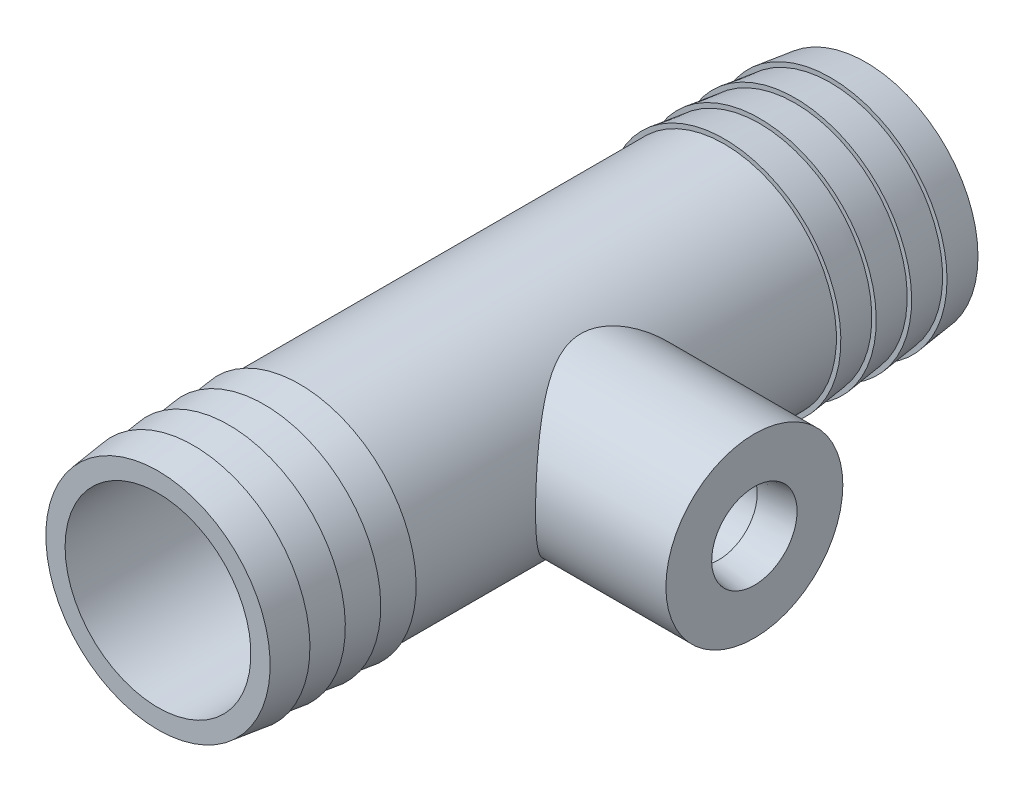
from build123d import *

# Parameters (mm, degrees)
BOSS_EXTRUDE1_DEPTH      = 10
BOSS_EXTRUDE1_DEPTH_BACK = 10
SKETCH1_R                = 10
BOSS_EXTRUDE2_DEPTH      = 40
BOSS_EXTRUDE2_DEPTH_BACK = 40
SKETCH11_R               = 12.675
SKETCH12_R               = 10.5
CUT_EXTRUDE6_DEPTH       = 87.401335837
SKETCH2_R                = 4.825
CUT_EXTRUDE7_DEPTH       = 30
LPATTERN1_COUNT          = 4
LPATTERN1_PITCH          = 4
LPATTERN2_COUNT          = 4
LPATTERN2_PITCH          = 4


with BuildPart() as part:
    # Sketch1 → Boss-Extrude1 (new, two sides: drawn at the far end of the back side and taken through both)
    with BuildSketch(Plane(origin=(0, 0, 0), x_dir=(0, 0, -1), z_dir=(1, 0, 0)).offset(-BOSS_EXTRUDE1_DEPTH_BACK)):
        Circle(SKETCH1_R)
    extrude(amount=BOSS_EXTRUDE1_DEPTH + BOSS_EXTRUDE1_DEPTH_BACK)

    # Sketch11 → Boss-Extrude2 (add, two sides: drawn at the far end of the back side and taken through both)
    with BuildSketch(Plane.XY.offset(-BOSS_EXTRUDE2_DEPTH_BACK)):
        with Locations((-17.400491433, 0)):
            Circle(SKETCH11_R)
    extrude(amount=BOSS_EXTRUDE2_DEPTH + BOSS_EXTRUDE2_DEPTH_BACK)

    # Sketch12 → Cut-Extrude6 (cut, through all)
    with BuildSketch(Plane(origin=(0, 0, -40), x_dir=(-1, 0, 0), z_dir=(0, 0, -1))):
        with Locations((17.400491433, 0)):
            Circle(SKETCH12_R)
    extrude(amount=-CUT_EXTRUDE6_DEPTH, mode=Mode.SUBTRACT)

    # Sketch2 → Cut-Extrude7 (cut)
    with BuildSketch(Plane(origin=(10, 0, 0), x_dir=(0, 0, -1), z_dir=(1, 0, 0))):
        Circle(SKETCH2_R)
    extrude(amount=-CUT_EXTRUDE7_DEPTH, mode=Mode.SUBTRACT)

    # Sketch13 → Revolve1 (revolve)
    with BuildSketch(Plane.XY):
        Polygon((10, 4.825), (6, 4.825), (6, 4.325), align=None)
    revolve1 = revolve(axis=Axis((10, 0, 0), (-1, 0, 0)))

    # LPattern1: Revolve1 ×4
    with Locations(*[(-i * LPATTERN1_PITCH, 0, 0) for i in range(1, LPATTERN1_COUNT)]):
        add(revolve1)

    # Sketch17 → Revolve2 (revolve)
    with BuildSketch(Plane(origin=(-17.400491433, 0, 0), x_dir=(0, 0, -1), z_dir=(1, 0, 0))):
        Polygon((-40, 12.675), (-36, 12.675), (-36, 13.175), align=None)
    revolve2 = revolve(axis=Axis((-17.400491433, 0, 40), (0, 0, -1)))

    # LPattern2: Revolve2 ×4
    with Locations(*[(0, 0, -i * LPATTERN2_PITCH) for i in range(1, LPATTERN2_COUNT)]):
        add(revolve2)

    # Mirror1 copy 1 sketch → Mirror1 copy 1 (revolve)
    with BuildSketch(Plane(origin=(-17.400491433, 0, 4), x_dir=(0, 0, 1), z_dir=(1, 0, 0))):
        Polygon((-40, -12.675), (-36, -12.675), (-36, -13.175), align=None)
    revolve(axis=Axis((-17.400491433, 0, -36), (0, 0, -1)))

    # Mirror1 copy 2 sketch → Mirror1 copy 2 (revolve)
    with BuildSketch(Plane(origin=(-17.400491433, 0, 8), x_dir=(0, 0, 1), z_dir=(1, 0, 0))):
        Polygon((-40, -12.675), (-36, -12.675), (-36, -13.175), align=None)
    revolve(axis=Axis((-17.400491433, 0, -32), (0, 0, -1)))

    # Mirror1 copy 3 sketch → Mirror1 copy 3 (revolve)
    with BuildSketch(Plane(origin=(-17.400491433, 0, 12), x_dir=(0, 0, 1), z_dir=(1, 0, 0))):
        Polygon((-40, -12.675), (-36, -12.675), (-36, -13.175), align=None)
    revolve(axis=Axis((-17.400491433, 0, -28), (0, 0, -1)))

    # Mirror1 copy 4 sketch → Mirror1 copy 4 (revolve)
    with BuildSketch(Plane(origin=(-17.400491433, 0, 0), x_dir=(0, 0, 1), z_dir=(1, 0, 0))):
        Polygon((-40, -12.675), (-36, -12.675), (-36, -13.175), align=None)
    revolve(axis=Axis((-17.400491433, 0, -40), (0, 0, -1)))


solid = part.part
